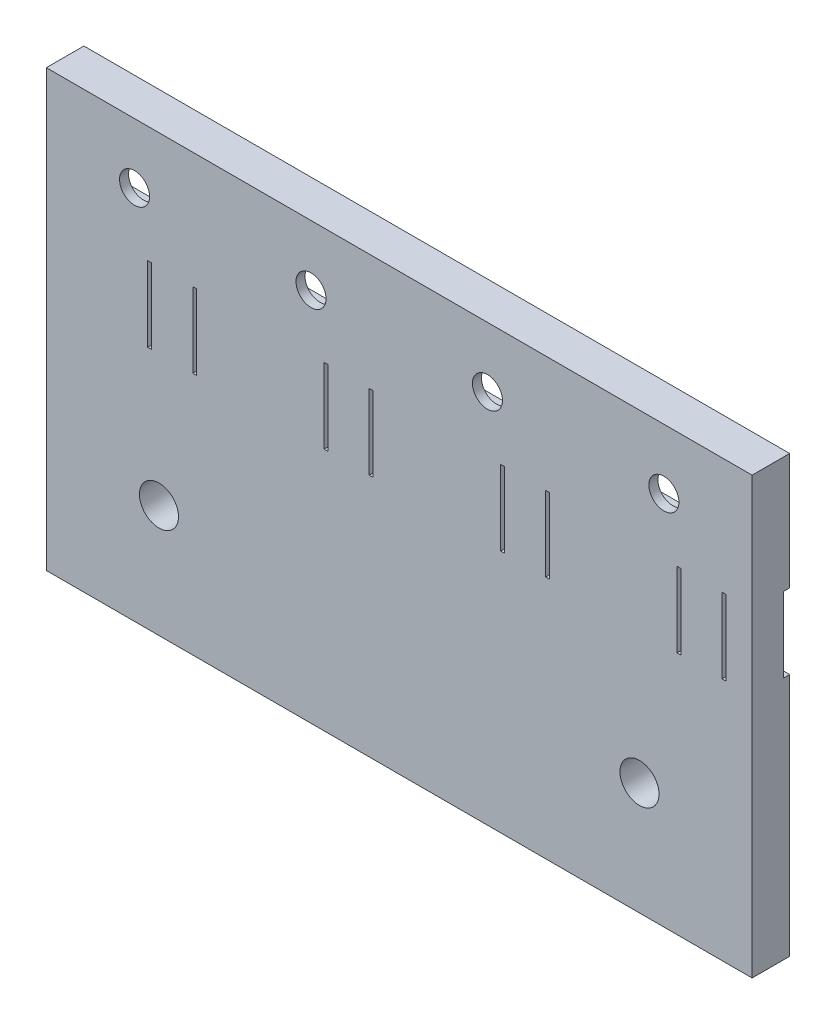
from build123d import *

# Parameters (mm, degrees)
SKETCH_1_W          = 94
SKETCH_1_H          = 28
SKETCH_1_R          = 2
SKETCH_1_H_2        = 30
SKETCH_1_R_2        = 2.6
EXTRUDE_1_DEPTH     = 5
SKETCH_2_W          = 20
SKETCH_2_H          = 10
SKETCH_2_H_2        = 9.9565682
SKETCH_2_H_3        = 9.91450181
CUT_EXTRUDE_1_DEPTH = 3.8
SKETCH_3_W          = 18
SKETCH_3_H          = 10
CUT_EXTRUDE_2_DEPTH = 0.8
SKETCH_4_W          = 0.5
SKETCH_4_H          = 10
CUT_EXTRUDE_3_DEPTH = 6


with BuildPart() as part:
    # 草图1 → 凸台-拉伸1 (new body)
    with BuildSketch(Plane.XY):
        with Locations((46.493576546, 13.050650803)):
            Rectangle(SKETCH_1_W, SKETCH_1_H)
        with Locations((11.243576546, 19.050650803)):
            Circle(SKETCH_1_R, mode=Mode.SUBTRACT)
        with Locations((34.743576546, 19.007901708)):
            Circle(SKETCH_1_R, mode=Mode.SUBTRACT)
        with Locations((58.243576546, 19.028934903)):
            Circle(SKETCH_1_R, mode=Mode.SUBTRACT)
        with Locations((81.743576546, 19.050650803)):
            Circle(SKETCH_1_R, mode=Mode.SUBTRACT)
        with Locations((46.493576546, -15.949349197)):
            Rectangle(SKETCH_1_W, SKETCH_1_H_2)
        with Locations((14.493576546, -15.949349197)):
            Circle(SKETCH_1_R_2, mode=Mode.SUBTRACT)
        with Locations((78.493576546, -15.949349197)):
            Circle(SKETCH_1_R_2, mode=Mode.SUBTRACT)
    extrude(amount=EXTRUDE_1_DEPTH)

    # 草图2 → 切除-拉伸1 (cut)
    with BuildSketch(Plane(origin=(0, 0, 0), x_dir=(-1, 0, 0), z_dir=(0, 0, -1))):
        with Locations((-81.743576546, 19.050650803)):
            Rectangle(SKETCH_2_W, SKETCH_2_H)
        with Locations((-58.243576546, 19.028934903)):
            Rectangle(SKETCH_2_W, SKETCH_2_H_2)
        with Locations((-34.743576546, 19.007901708)):
            Rectangle(SKETCH_2_W, SKETCH_2_H_3)
        with Locations((-11.243576546, 19.050650803)):
            Rectangle(SKETCH_2_W, SKETCH_2_H)
    extrude(amount=-CUT_EXTRUDE_1_DEPTH, mode=Mode.SUBTRACT)

    # 草图3 → 切除-拉伸2 (cut)
    with BuildSketch(Plane(origin=(0, 0, 0), x_dir=(-1, 0, 0), z_dir=(0, 0, -1))):
        with Locations((-4.493576546, 6.550650803)):
            Rectangle(SKETCH_3_W, SKETCH_3_H)
        with Locations((-27.993576546, 6.550650803)):
            Rectangle(SKETCH_3_W, SKETCH_3_H)
        with Locations((-51.493576546, 6.550650803)):
            Rectangle(SKETCH_3_W, SKETCH_3_H)
        with Locations((-74.993576546, 6.550650803)):
            Rectangle(SKETCH_3_W, SKETCH_3_H)
        with Locations((-98.493576546, 6.550650803)):
            Rectangle(SKETCH_3_W, SKETCH_3_H)
    extrude(amount=-CUT_EXTRUDE_2_DEPTH, mode=Mode.SUBTRACT)

    # 草图4 → 切除-拉伸3 (cut, through all)
    with BuildSketch(Plane(origin=(0, 0, 0), x_dir=(-1, 0, 0), z_dir=(0, 0, -1))):
        with Locations((-13.243576546, 6.550650803)):
            Rectangle(SKETCH_4_W, SKETCH_4_H)
        with Locations((-19.243576546, 6.550650803)):
            Rectangle(SKETCH_4_W, SKETCH_4_H)
        with Locations((-36.743576546, 6.550650803)):
            Rectangle(SKETCH_4_W, SKETCH_4_H)
        with Locations((-42.743576546, 6.550650803)):
            Rectangle(SKETCH_4_W, SKETCH_4_H)
        with Locations((-60.243576546, 6.550650803)):
            Rectangle(SKETCH_4_W, SKETCH_4_H)
        with Locations((-66.243576546, 6.550650803)):
            Rectangle(SKETCH_4_W, SKETCH_4_H)
        with Locations((-83.743576546, 6.550650803)):
            Rectangle(SKETCH_4_W, SKETCH_4_H)
        with Locations((-89.743576546, 6.550650803)):
            Rectangle(SKETCH_4_W, SKETCH_4_H)
    extrude(amount=-CUT_EXTRUDE_3_DEPTH, mode=Mode.SUBTRACT)


solid = part.part
